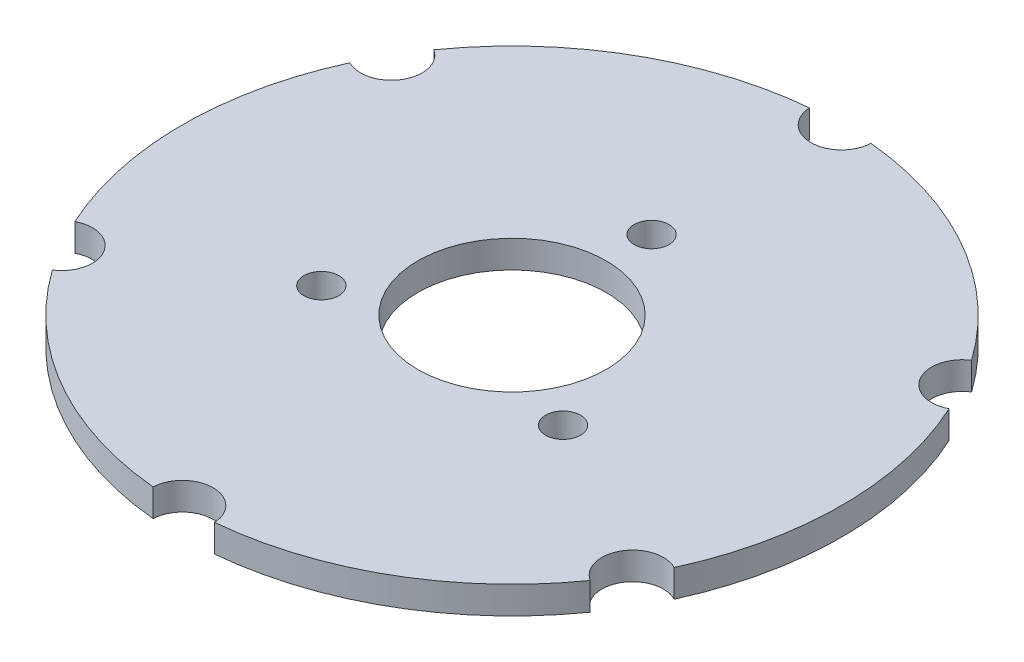
from build123d import *

# Parameters (mm, degrees)
SKETCH1_R           = 59.99988
SKETCH1_R_2         = 17.145
SKETCH1_R_3         = 3.175
BOSS_EXTRUDE1_DEPTH = 5
SKETCH2_R           = 5.59943
CUT_EXTRUDE1_DEPTH  = 6
CIRPATTERN1_COUNT   = 6


with BuildPart() as part:
    # Sketch1 → Boss-Extrude1 (new body)
    with BuildSketch(Plane(origin=(0, 0, 0), x_dir=(1, 0, 0), z_dir=(0, 1, 0))):
        Circle(SKETCH1_R)
        Circle(SKETCH1_R_2, mode=Mode.SUBTRACT)
        with Locations((21.997045256, -12.7)):
            Circle(SKETCH1_R_3, mode=Mode.SUBTRACT)
        with Locations((0, 25.4)):
            Circle(SKETCH1_R_3, mode=Mode.SUBTRACT)
        with Locations((-21.997045256, -12.7)):
            Circle(SKETCH1_R_3, mode=Mode.SUBTRACT)
    extrude(amount=BOSS_EXTRUDE1_DEPTH)

    # Sketch2 → Cut-Extrude1 (cut, through all)
    with BuildSketch(Plane(origin=(0, 5, 0), x_dir=(1, 0, 0), z_dir=(0, 1, 0))):
        with Locations((0, 59.99988)):
            Circle(SKETCH2_R)
    cut_extrude1 = extrude(amount=-CUT_EXTRUDE1_DEPTH, mode=Mode.SUBTRACT)

    # CirPattern1: Cut-Extrude1 ×6 about axis
    cirpattern1_axis = Axis((0, 0, 0), (0, 1, 0))
    for i in range(1, CIRPATTERN1_COUNT):
        add(cut_extrude1.rotate(cirpattern1_axis, i * 360 / CIRPATTERN1_COUNT), mode=Mode.SUBTRACT)


solid = part.part
